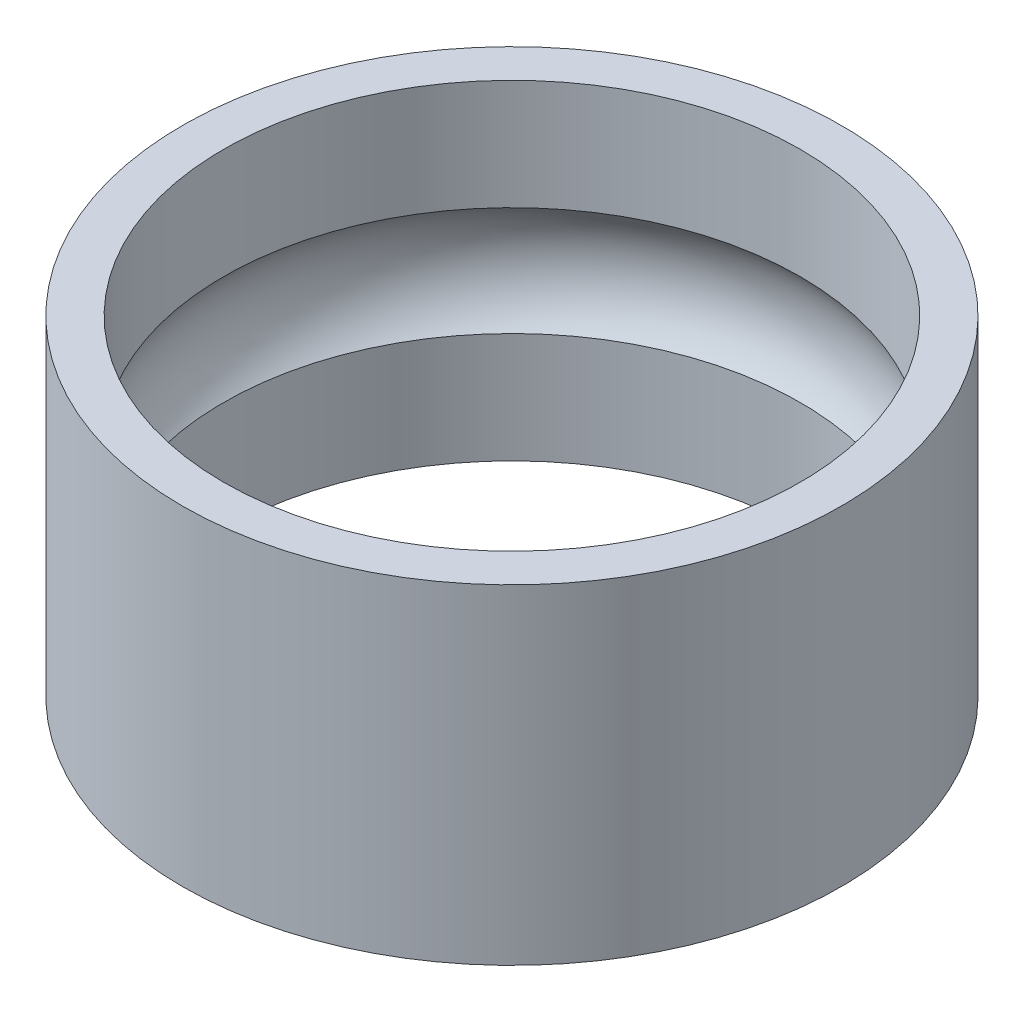
from build123d import *

# Parameters (mm, degrees)
DIAPROFILES_R         = 4
DIAPROFILES_R_2       = 3.5
DIAPROFILE_DEPTH      = 2
BEARINGPATHPROFILES_R = 1


with BuildPart() as part:
    # DiaProfileS → DiaProfile (new body, symmetric)
    with BuildSketch(Plane(origin=(0, 0, 0), x_dir=(1, 0, 0), z_dir=(0, 1, 0))):
        Circle(DIAPROFILES_R)
        Circle(DIAPROFILES_R_2, mode=Mode.SUBTRACT)
    extrude(amount=DIAPROFILE_DEPTH, both=True)

    # BearingPathProfileS → BearingPathProfile (revolve, cut)
    with BuildSketch(Plane.XY):
        with Locations((2.75, 0)):
            Circle(BEARINGPATHPROFILES_R)
    revolve(axis=Axis((0, 2, 0), (0, -1, 0)), mode=Mode.SUBTRACT)


solid = part.part
